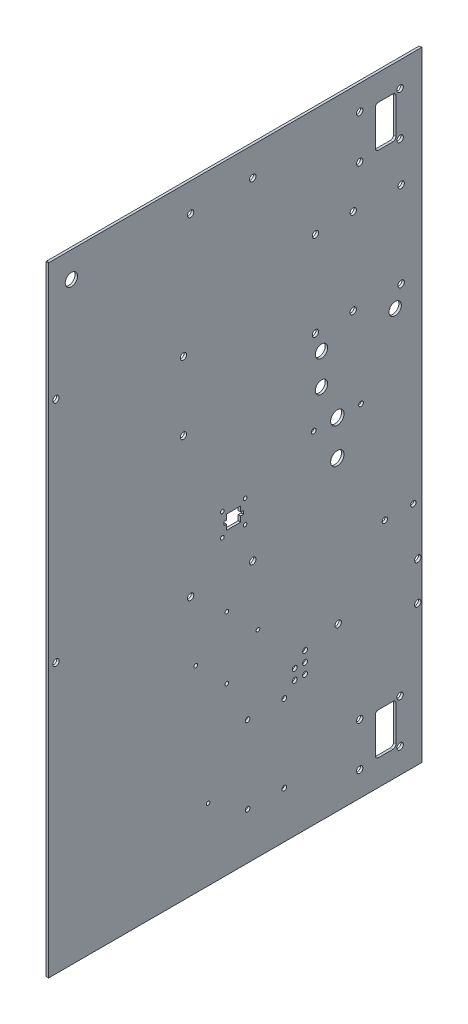
from build123d import *

# Parameters (mm, degrees)
SKETCH1_W                                   = 499.3132
SKETCH1_H                                   = 797.0266
SIDEPANEL_DEPTH                             = 3.0734
SKETCH2_R                                   = 2.8956
TOPBOTTOMHOLEMASTER_DEPTH                   = 4.0734
LPATTERN1_COUNT                             = 4
LPATTERN1_PITCH                             = 127.067733333
SKETCH3_R                                   = 2.8956
REARHOLESMASTER_DEPTH                       = 4.0734
LPATTERN2_COUNT                             = 4
LPATTERN2_PITCH                             = 211.7344
SKETCH4_W                                   = 19.05
SKETCH4_H                                   = 19.05
SKETCH4_W_2                                 = 22.86
CORNERCUTS_DEPTH                            = 4.0734
F_8_CLEARANCE_HOLE4_BRAIN_MOUNT_D           = 7.8232
F_8_CLEARANCE_HOLE3_PUMP_MOUNTS_D           = 4.4958
SKETCH17_W                                  = 25.4
SKETCH17_H                                  = 50.8
CABLE_PASS_THROUGH_DEPTH                    = 4.0734
F_8_CLEARANCE_HOLE1_PASS_THROUGH_MOUNTING_D = 7.8232
CUT_EXTRUDE1_DEPTH                          = 2.54
F_8_CLEARANCE_HOLE_HX_MOUNT_D               = 7.8232
SKETCH42_R                                  = 7.578725
SKETCH42_R_2                                = 7.5819
COOLANT_HOSE_PASS_THROUGH_DEPTH             = 4.0734
SKETCH43_R                                  = 7.5819
AIR_FLUSH_IN_OUT_DEPTH                      = 4.0734
F_8_CLEARANCE_HOLE2_AIR_FLUSH_OUT_MOUNT_D   = 7.8232
F_8_CLEARANCE_HOLE4_PANEL_MOUNTS_D          = 7.8232
FILLET1_R                                   = 3.81
SKETCH50_OUTSIDE_W                          = 689.418
SKETCH50_OUTSIDE_H                          = 987.13
SKETCH50_OUTSIDE_R                          = 8.1915
SENSOR_MOUNTING_DEPTH                       = 4.0734
F_8_CLEARANCE_HOLE1_D                       = 4.4958
F_12_CLEARANCE_HOLE1_D                      = 5.7912
FILLET2_R                                   = 0.127
F_4_CLEARANCE_HOLE_COMPRESSOR_DRIVER_D      = 5.7912
F_1_4_CLEARANCE_HOLE_BALL_VALVE_U_BOLT_D    = 6.5278
AERATION_PUMP_8_CLEARANCE_HOLE1_D           = 4.3053
NUTRIENT_HOLES_R                            = 3.0226
NUTRIENT_HOSES_DEPTH                        = 4.0734
LPATTERN3_COUNT                             = 3
LPATTERN3_PITCH                             = 12.7
LPATTERN3_COUNT_DIR2                        = 3
LPATTERN3_PITCH_DIR2                        = 12.7
SKETCH61_W                                  = 508.2032
SKETCH61_H                                  = 809.7266
SKETCH61_W_2                                = 457.4032
SKETCH61_H_2                                = 758.9266
CUT_EXTRUDE2_DEPTH                          = 4.0734


with BuildPart() as part:
    # Sketch1 → SidePanel (new body)
    with BuildSketch(Plane(origin=(0, 0, 0), x_dir=(0, 0, -1), z_dir=(1, 0, 0))):
        Rectangle(SKETCH1_W, SKETCH1_H)
    extrude(amount=SIDEPANEL_DEPTH)

    # Sketch2 → TopBottomHoleMaster (cut, through all)
    with BuildSketch(Plane(origin=(3.0734, 0, 0), x_dir=(0, 0, -1), z_dir=(1, 0, 0))):
        with Locations((192.5066, 388.9883)):
            Circle(SKETCH2_R)
        with Locations((192.5066, -388.9883)):
            Circle(SKETCH2_R)
    topbottomholemaster = extrude(amount=-TOPBOTTOMHOLEMASTER_DEPTH, mode=Mode.SUBTRACT)

    # LPattern1: TopBottomHoleMaster ×4
    with Locations(*[(0, 0, i * LPATTERN1_PITCH) for i in range(1, LPATTERN1_COUNT)]):
        add(topbottomholemaster, mode=Mode.SUBTRACT)

    # Sketch3 → RearHolesMaster (cut, through all)
    with BuildSketch(Plane(origin=(3.0734, 0, 0), x_dir=(0, 0, -1), z_dir=(1, 0, 0))):
        with Locations((-236.3216, 315.8617)):
            Circle(SKETCH3_R)
        with Locations((240.1316, 315.8617)):
            Circle(SKETCH3_R)
    rearholesmaster = extrude(amount=-REARHOLESMASTER_DEPTH, mode=Mode.SUBTRACT)

    # LPattern2: RearHolesMaster ×4
    with Locations(*[(0, -i * LPATTERN2_PITCH, 0) for i in range(1, LPATTERN2_COUNT)]):
        add(rearholesmaster, mode=Mode.SUBTRACT)

    # Sketch4 → CornerCuts (cut, through all)
    with BuildSketch(Plane.ZY):
        with Locations((-240.1316, 388.9883)):
            Rectangle(SKETCH4_W, SKETCH4_H)
        with Locations((238.2266, 388.9883)):
            Rectangle(SKETCH4_W_2, SKETCH4_H)
        with Locations((-240.1316, -388.9883)):
            Rectangle(SKETCH4_W, SKETCH4_H)
    extrude(amount=-CORNERCUTS_DEPTH, mode=Mode.SUBTRACT)

    # #8 Clearance Hole4 Brain Mount (through all)
    with Locations(Plane.ZY):
        with Locations((-23.3934, 344.4367), (52.8066, 344.4367), (52.8066, -61.9633), (-23.3934, -61.9633), (-146.4564, 141.8717), (-146.4564, 247.2817), (61.5696, 197.49262), (61.5696, 113.41862)):
            Hole(F_8_CLEARANCE_HOLE4_BRAIN_MOUNT_D / 2)

    # #8 Clearance Hole3 Pump Mounts (through all)
    with Locations(Plane.ZY):
        with Locations((46.4566, -138.1633), (8.3566, -100.0633), (8.3566, -176.2633), (-29.7434, -138.1633)):
            Hole(F_8_CLEARANCE_HOLE3_PUMP_MOUNTS_D / 2)

    # Sketch17 → Cable Pass Through (cut, through all)
    with BuildSketch(Plane.ZY):
        with Locations((-186.1566, 322.3133)):
            Rectangle(SKETCH17_W, SKETCH17_H)
        with Locations((-186.1566, -322.3133)):
            Rectangle(SKETCH17_W, SKETCH17_H)
    extrude(amount=-CABLE_PASS_THROUGH_DEPTH, mode=Mode.SUBTRACT)

    # #8 Clearance Hole1 Pass through Mounting holes (through all)
    with Locations(Plane(origin=(3.0734, 0, 0), x_dir=(0, 0, -1), z_dir=(1, 0, 0))):
        with Locations((154.4066, -348.9833), (203.9366, -348.9833), (203.9366, -295.6433), (154.4066, -295.6433), (154.4066, 348.9833), (203.9366, 348.9833), (203.9366, 295.6433), (154.4066, 295.6433)):
            Hole(F_8_CLEARANCE_HOLE1_PASS_THROUGH_MOUNTING_D / 2)

    # Sketch39 → Cut-Extrude1 (cut)
    with BuildSketch(Plane.ZY):
        Polygon((-230.2256, 398.5133), (-230.6066, 398.5133), (-230.6066, 379.4633), (-249.6566, 379.4633), (-249.6566, 379.0823), (-230.2256, 379.0823), align=None)
        Polygon((-249.6566, -379.0823), (-249.6566, -379.4633), (-230.6066, -379.4633), (-230.6066, -398.5133), (-230.2256, -398.5133), (-230.2256, -379.0823), align=None)
        Polygon((226.7966, 398.5133), (226.4156, 398.5133), (226.4156, 379.0823), (249.6566, 379.0823), (249.6566, 379.4633), (226.7966, 379.4633), align=None)
    extrude(amount=-CUT_EXTRUDE1_DEPTH, mode=Mode.SUBTRACT)

    # #8 Clearance Hole -hx mount (through all)
    with Locations(Plane(origin=(3.0734, 0, 0), x_dir=(0, 0, -1), z_dir=(1, 0, 0))):
        with Locations((205.2066, 246.1133), (205.2066, 141.1133), (100.2066, 141.1133), (100.2066, 246.1133)):
            Hole(F_8_CLEARANCE_HOLE_HX_MOUNT_D / 2)

    # Sketch42 → Coolant hose pass through (cut, through all)
    with BuildSketch(Plane(origin=(3.0734, 0, 0), x_dir=(0, 0, -1), z_dir=(1, 0, 0))):
        with Locations((197.8406, 118.5073)):
            Circle(SKETCH42_R)
        with Locations((107.5726, 118.5073)):
            Circle(SKETCH42_R_2)
    extrude(amount=-COOLANT_HOSE_PASS_THROUGH_DEPTH, mode=Mode.SUBTRACT)

    # Sketch43 → Air flush in/out (cut, through all)
    with BuildSketch(Plane(origin=(3.0734, 0, 0), x_dir=(0, 0, -1), z_dir=(1, 0, 0))):
        with Locations((-198.8566, 347.7133)):
            Circle(SKETCH43_R)
        with Locations((107.5726, 80.4073)):
            Circle(SKETCH43_R)
    extrude(amount=-AIR_FLUSH_IN_OUT_DEPTH, mode=Mode.SUBTRACT)

    # #8 Clearance Hole2 Air Flush Out mount (through all)
    with Locations(Plane(origin=(3.0734, 0, 0), x_dir=(0, 0, -1), z_dir=(1, 0, 0))):
        with Locations((225.5266, -160.7693), (225.5266, -208.0133), (128.067808498, -181.154848387)):
            Hole(F_8_CLEARANCE_HOLE2_AIR_FLUSH_OUT_MOUNT_D / 2)

    # #8 Clearance Hole4 Panel Mounts (through all)
    with Locations(Plane(origin=(3.0734, 0, 0), x_dir=(0, 0, -1), z_dir=(1, 0, 0))):
        with Locations((-217.7034, 230.1367), (-217.7034, -49.2633)):
            Hole(F_8_CLEARANCE_HOLE4_PANEL_MOUNTS_D / 2)

    # Fillet1
    fillet1_edges = [part.edges().sort_by_distance(p)[0] for p in [
        (1.5367, 296.9133, -198.8566),
        (1.5367, 347.7133, -198.8566),
        (1.5367, 347.7133, -173.4566),
        (1.5367, 296.9133, -173.4566),
        (1.5367, -347.7133, -173.4566),
        (1.5367, -347.7133, -198.8566),
        (1.5367, -296.9133, -198.8566),
        (1.5367, -296.9133, -173.4566),
    ]]
    fillet(fillet1_edges, radius=FILLET1_R)

    # Sketch50 outside → Sensor Mounting (cut, through all)
    with BuildSketch(Plane(origin=(3.0734, 0, 0), x_dir=(0, 0, -1), z_dir=(1, 0, 0))):
        Rectangle(SKETCH50_OUTSIDE_W, SKETCH50_OUTSIDE_H)
        Polygon((230.6066, -379.4633), (249.6566, -379.4633), (249.6566, 379.4633), (230.6066, 379.4633), (230.6066, 398.5133), (-226.7966, 398.5133), (-226.7966, 379.4633), (-249.6566, 379.4633), (-249.6566, -398.5133), (230.6066, -398.5133), align=None, mode=Mode.SUBTRACT)
        with Locations((127, -4.8133)):
            Circle(SKETCH50_OUTSIDE_R)
        with Locations((127, 38.3667)):
            Circle(SKETCH50_OUTSIDE_R)
        Polygon((-8.625, 3.8117), (8.625, 3.8117), (8.625, -2.6883), (12.125, -2.6883), (12.125, -6.9383), (8.625, -6.9383), (8.625, -13.4383), (-8.625, -13.4383), (-8.625, -6.9383), (-12.125, -6.9383), (-12.125, -2.6883), (-8.625, -2.6883), align=None)
    extrude(amount=-SENSOR_MOUNTING_DEPTH, mode=Mode.SUBTRACT)

    # #8 Clearance Hole1 (through all)
    with Locations(Plane(origin=(3.0734, 0, 0), x_dir=(0, 0, -1), z_dir=(1, 0, 0))):
        with Locations((-13.97, 9.1567), (13.97, 9.1567), (13.97, -18.7833), (-13.97, -18.7833)):
            Hole(F_8_CLEARANCE_HOLE1_D / 2)

    # #12 Clearance Hole1 (through all)
    with Locations(Plane(origin=(3.0734, 0, 0), x_dir=(0, 0, -1), z_dir=(1, 0, 0))):
        with Locations((98, 38.3667), (156, 38.3667)):
            Hole(F_12_CLEARANCE_HOLE1_D / 2)

    # Fillet2
    fillet2_edges = [part.edges().sort_by_distance(p)[0] for p in [
        (1.5367, -2.6883, 8.625),
        (1.5367, 3.8117, 8.625),
        (1.5367, 3.8117, -8.625),
        (1.5367, -2.6883, -8.625),
        (1.5367, -2.6883, -12.125),
        (1.5367, -6.9383, -12.125),
        (1.5367, -6.9383, -8.625),
        (1.5367, -13.4383, -8.625),
        (1.5367, -13.4383, 8.625),
        (1.5367, -6.9383, 8.625),
        (1.5367, -6.9383, 12.125),
        (1.5367, -2.6883, 12.125),
    ]]
    fillet(fillet2_edges, radius=FILLET2_R)

    # #4 Clearance Hole compressor driver (through all)
    with Locations(Plane.ZY):
        with Locations((-17.0434, -227.3133), (-62.0434, -227.3133), (-62.0434, -322.3133), (-17.0434, -322.3133)):
            Hole(F_4_CLEARANCE_HOLE_COMPRESSOR_DRIVER_D / 2)

    # 1/4 Clearance Hole ball valve u bolt (through all)
    with Locations(Plane(origin=(3.0734, 0, 0), x_dir=(0, 0, -1), z_dir=(1, 0, 0))):
        with Locations((220.1418, -99.7331), (185.2168, -99.7331)):
            Hole(F_1_4_CLEARANCE_HOLE_BALL_VALVE_U_BOLT_D / 2)

    # Aeration Pump #8 Clearance Hole1 (through all)
    with Locations(Plane(origin=(3.0734, 0, 0), x_dir=(0, 0, -1), z_dir=(1, 0, 0))):
        with Locations((-31.37535, -291.753925)):
            Hole(AERATION_PUMP_8_CLEARANCE_HOLE1_D / 2)

    # Nutrient Holes → Nutrient Hoses (cut, through all)
    with BuildSketch(Plane(origin=(3.0734, 0, 0), x_dir=(0, 0, -1), z_dir=(1, 0, 0))):
        with Locations((87.4434, -214.3633)):
            Circle(NUTRIENT_HOLES_R)
    nutrient_hoses = extrude(amount=-NUTRIENT_HOSES_DEPTH, mode=Mode.SUBTRACT)

    # LPattern3: Nutrient Hoses 3 × 3, 4 skipped
    with Locations(*[(0, i * LPATTERN3_PITCH, j * LPATTERN3_PITCH_DIR2) for i in range(LPATTERN3_COUNT) for j in range(LPATTERN3_COUNT_DIR2) if (i, j) not in ((0, 0), (0, 2), (1, 2), (2, 1), (2, 2))]):
        add(nutrient_hoses, mode=Mode.SUBTRACT)

    # Sketch61 → Cut-Extrude2 (cut, through all)
    with BuildSketch(Plane(origin=(3.0734, 0, 0), x_dir=(0, 0, -1), z_dir=(1, 0, 0))):
        with Locations((1.905, 0)):
            Rectangle(SKETCH61_W, SKETCH61_H)
        with Locations((1.905, 0)):
            Rectangle(SKETCH61_W_2, SKETCH61_H_2, mode=Mode.SUBTRACT)
    extrude(amount=-CUT_EXTRUDE2_DEPTH, mode=Mode.SUBTRACT)


solid = part.part
